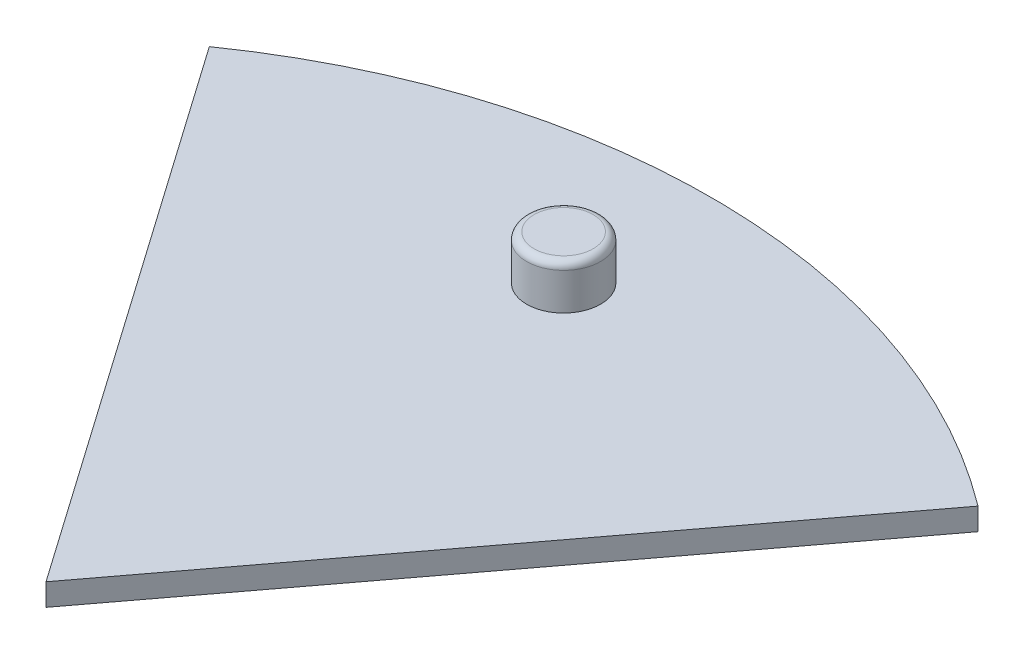
from build123d import *

# Parameters (mm, degrees)
BOSS_EXTRUDE1_DEPTH = 1.5
BOSS_EXTRUDE2_DEPTH = 1.5
SKETCH4_R           = 2.5
BOSS_EXTRUDE3_DEPTH = 3
FILLET1_R           = 0.5


with BuildPart() as part:
    # Sketch2 → Boss-Extrude1 (new body)
    with BuildSketch(Plane(origin=(0, 0, 0), x_dir=(1, 0, 0), z_dir=(0, 1, 0))):
        with BuildLine():
            Line((-25.815069681, 36.858949759), (0, 0))
            Line((0, 0), (27.07764911, 35.94163211))
            ThreePointArc((27.07764911, 35.94163211), (0.780317, 44.993233996), (-25.815069681, 36.858949759))
        make_face()
    extrude(amount=BOSS_EXTRUDE1_DEPTH)

    # Sketch3 → Boss-Extrude2 (add)
    with BuildSketch(Plane.XZ):
        with BuildLine():
            Line((0, -34.375), (10, -34.375))
            ThreePointArc((10, -34.375), (10.625, -35), (10, -35.625))
            Line((10, -35.625), (0, -35.625))
            ThreePointArc((0, -35.625), (-0.625, -35), (0, -34.375))
        make_face()
    extrude(amount=BOSS_EXTRUDE2_DEPTH)

    # Sketch4 → Boss-Extrude3 (add)
    with BuildSketch(Plane(origin=(0, 1.5, 0), x_dir=(1, 0, 0), z_dir=(0, 1, 0))):
        with Locations((0, 35)):
            Circle(SKETCH4_R)
    extrude(amount=BOSS_EXTRUDE3_DEPTH)

    # Fillet1
    fillet1_edges = [part.edges().sort_by_distance(p)[0] for p in [
        (-2.5, 4.5, -35),
    ]]
    fillet(fillet1_edges, radius=FILLET1_R)


solid = part.part
